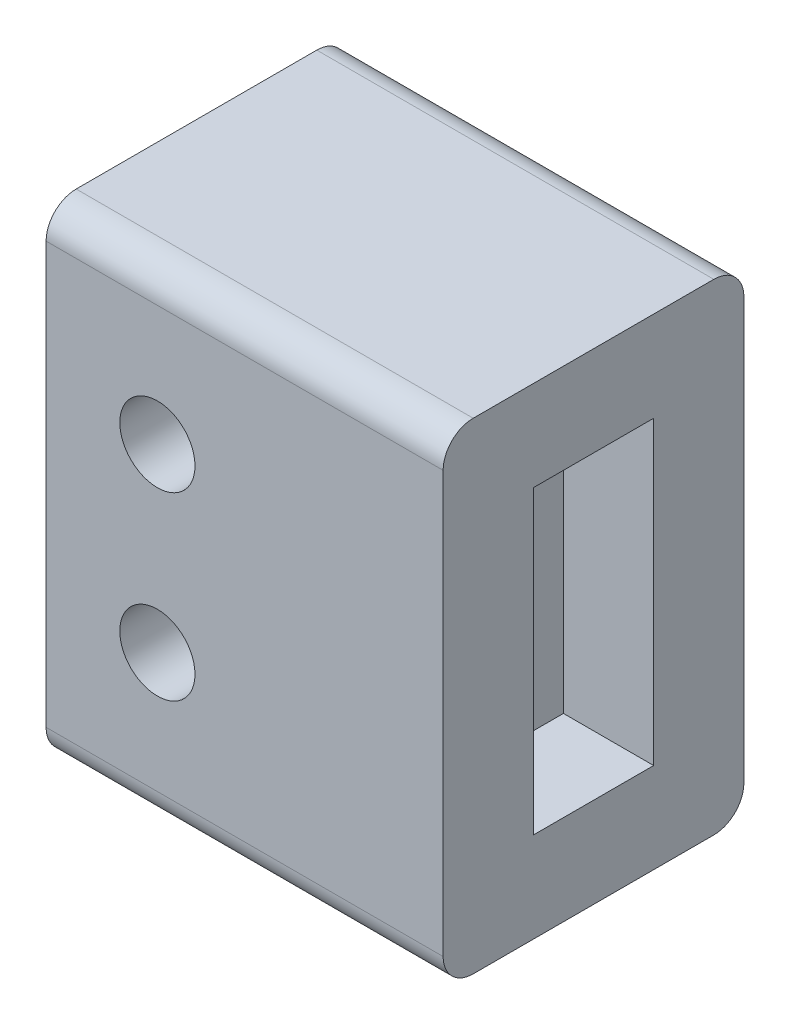
from build123d import *

# Parameters (mm, degrees)
SKETCH1_W               = 7.2
SKETCH1_H               = 12
BOSS_EXTRUDE2_DEPTH     = 6
SHELL1_T                = 2
SKETCH4_R               = 1.25
CUT_EXTRUDE2_DEPTH      = 28.897132469
CUT_EXTRUDE2_DEPTH_BACK = 2
SKETCH5_W               = 10
SKETCH5_H               = 16
BOSS_EXTRUDE3_DEPTH     = 4
SHELL2_T                = -3
FILLET1_R               = 1


with BuildPart() as part:
    # Sketch1 → Boss-Extrude2 (new body)
    with BuildSketch(Plane.XY):
        with Locations((19.9, 0)):
            Rectangle(SKETCH1_W, SKETCH1_H)
    extrude(amount=BOSS_EXTRUDE2_DEPTH)

    # Shell1
    shell1_openings = [part.faces().sort_by_distance(p)[0] for p in [
        (16.3, 0, 3),
    ]]
    offset(amount=SHELL1_T, openings=shell1_openings, kind=Kind.INTERSECTION)

    # Sketch4 → Cut-Extrude2 (cut, two sides)
    with BuildSketch(Plane.XY) as cut_extrude2_sk:
        with Locations((20, -3)):
            Circle(SKETCH4_R)
        with Locations((20, 3)):
            Circle(SKETCH4_R)
    extrude(amount=CUT_EXTRUDE2_DEPTH, mode=Mode.SUBTRACT)
    extrude(cut_extrude2_sk.sketch, amount=-CUT_EXTRUDE2_DEPTH_BACK, mode=Mode.SUBTRACT)

    # Sketch5 → Boss-Extrude3 (add)
    with BuildSketch(Plane(origin=(25.5, 0, 0), x_dir=(0, 0, -1), z_dir=(1, 0, 0))):
        with Locations((-3, 0)):
            Rectangle(SKETCH5_W, SKETCH5_H)
    extrude(amount=BOSS_EXTRUDE3_DEPTH)

    # Shell2
    shell2_openings = [part.faces().sort_by_distance(p)[0] for p in [
        (29.5, 0, 3),
    ]]
    offset(amount=SHELL2_T, openings=shell2_openings, kind=Kind.INTERSECTION)

    # Fillet1
    fillet1_edges = [part.edges().sort_by_distance(p)[0] for p in [
        (22.9, -8, 8),
        (22.9, -8, -2),
        (22.9, 8, -2),
        (22.9, 8, 8),
    ]]
    fillet(fillet1_edges, radius=FILLET1_R)


solid = part.part
